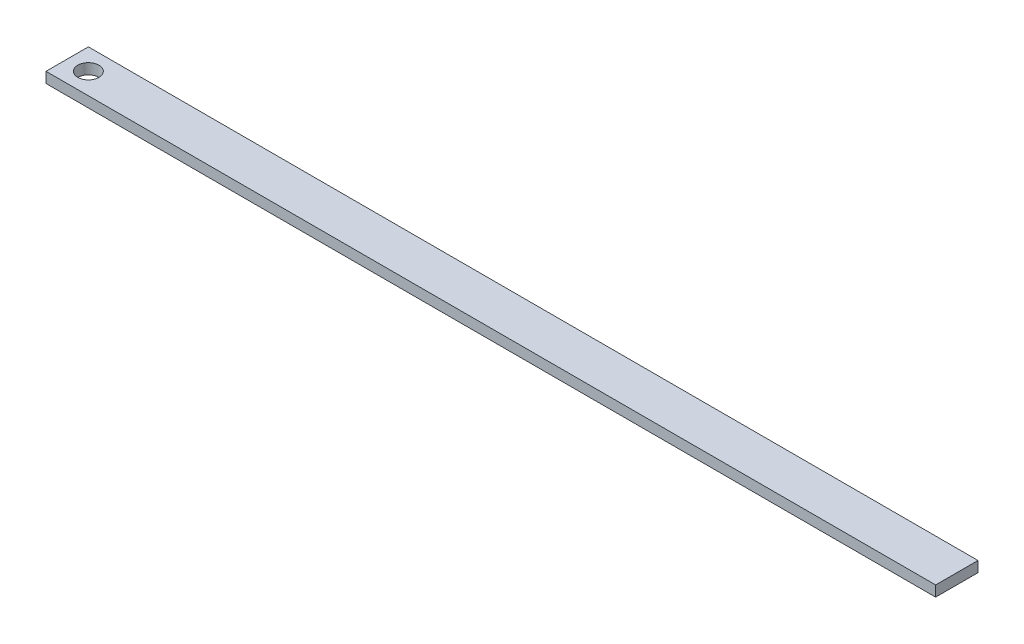
from build123d import *

# Parameters (mm, degrees)
CONTACT_BODY_SKETCH_W = 21
CONTACT_BODY_SKETCH_H = 1
CONTACT_BODY_SKETCH_R = 0.25
CONTACT_BODY_DEPTH    = 0.25


with BuildPart() as part:
    # Contact_body_sketch → Contact_body (new body)
    with BuildSketch(Plane(origin=(0, 0, 0), x_dir=(1, 0, 0), z_dir=(0, 1, 0))):
        Rectangle(CONTACT_BODY_SKETCH_W, CONTACT_BODY_SKETCH_H)
        with Locations((-10, 0)):
            Circle(CONTACT_BODY_SKETCH_R, mode=Mode.SUBTRACT)
    extrude(amount=CONTACT_BODY_DEPTH)


solid = part.part
